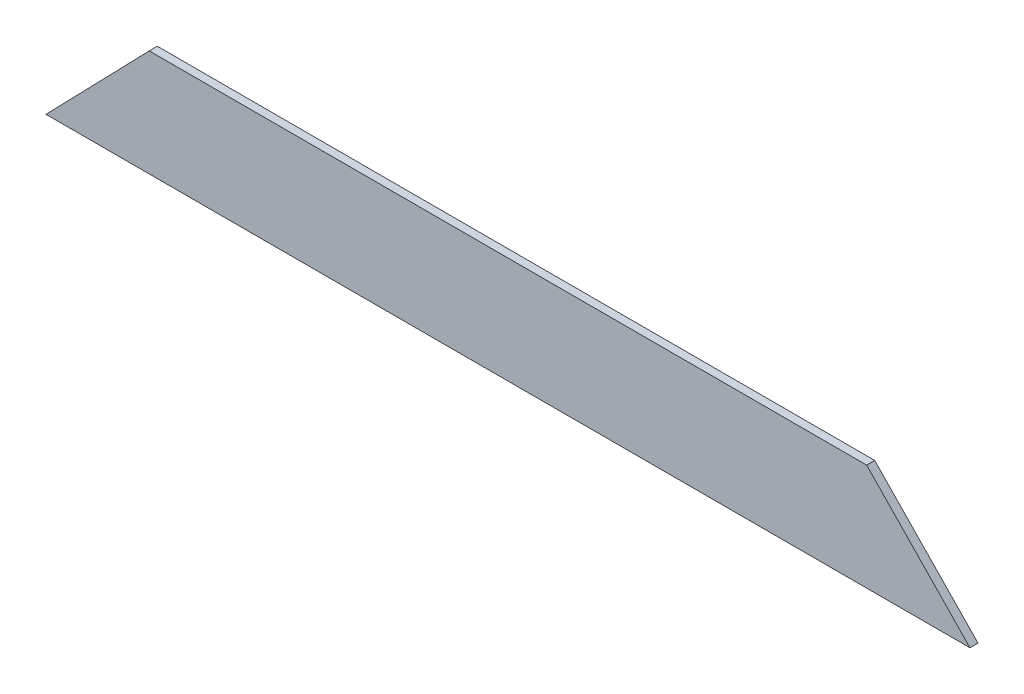
from build123d import *

# Parameters (mm, degrees)
BOSS_EXTRUDE1_DEPTH = 18.25625


with BuildPart() as part:
    # Sketch1 → Boss-Extrude1 (new body)
    with BuildSketch(Plane.XY):
        Polygon((1226.804990723, 308.776112521), (992.969022955, 550.076112521), (-631.281602045, 550.076112521), (-865.117569814, 308.776112521), (-681.751009277, 308.776112521), align=None)
    extrude(amount=BOSS_EXTRUDE1_DEPTH)


solid = part.part
